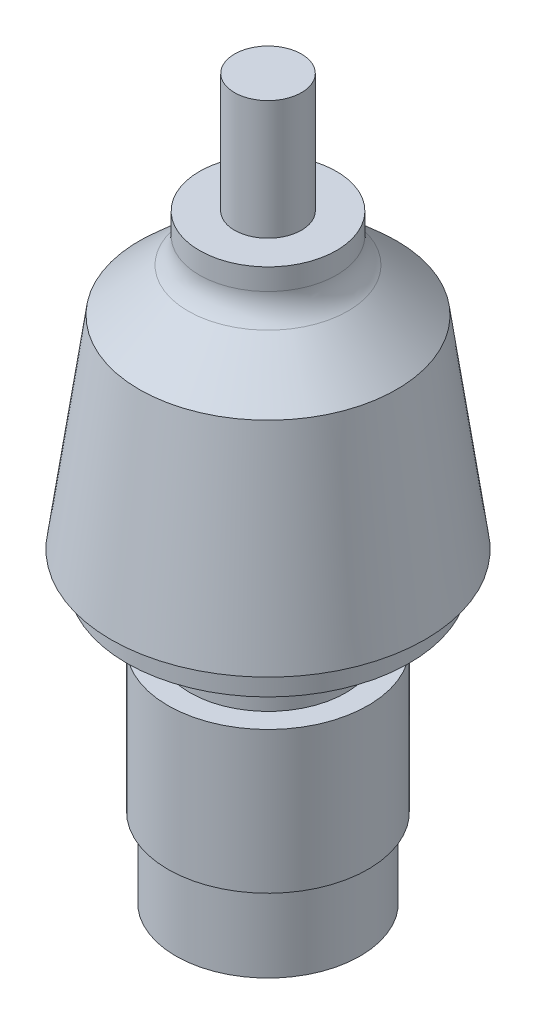
from build123d import *

# Parameters (mm, degrees)
SKETCH1_R           = 13.7541
BOSS_EXTRUDE1_DEPTH = 11.7856
SKETCH2_R           = 14.9225
BOSS_EXTRUDE2_DEPTH = 21.1582
SKETCH3_R           = 11.6205
BOSS_EXTRUDE3_DEPTH = 8.5598
SKETCH4_R           = 21.082
BOSS_EXTRUDE4_DEPTH = 4.2164
SKETCH6_R           = 19.2024
SKETCH5_R           = 23.4315
SKETCH8_R           = 10.2235
SKETCH9_R           = 10.2235
BOSS_EXTRUDE5_DEPTH = 5.461
SKETCH11_R          = 4.9911
BOSS_EXTRUDE6_DEPTH = 17.78
FILLET1_R           = 5.08


with BuildPart() as part:
    # Sketch1 → Boss-Extrude1 (new body)
    with BuildSketch(Plane(origin=(0, 0, 0), x_dir=(1, 0, 0), z_dir=(0, 1, 0))):
        with Locations(Location((0, 0, 0), (0, 0, 270))):
            Circle(SKETCH1_R)
    extrude(amount=BOSS_EXTRUDE1_DEPTH)

    # Sketch2 → Boss-Extrude2 (add)
    with BuildSketch(Plane(origin=(0, 11.7856, 0), x_dir=(1, 0, 0), z_dir=(0, 1, 0))):
        with Locations(Location((0, 0, 0), (0, 0, 270))):
            Circle(SKETCH2_R)
    extrude(amount=BOSS_EXTRUDE2_DEPTH)

    # Sketch3 → Boss-Extrude3 (add)
    with BuildSketch(Plane(origin=(0, 32.9438, 0), x_dir=(1, 0, 0), z_dir=(0, 1, 0))):
        with Locations(Location((0, 0, 0), (0, 0, 270))):
            Circle(SKETCH3_R)
    extrude(amount=BOSS_EXTRUDE3_DEPTH)

    # Sketch4 → Boss-Extrude4 (add)
    with BuildSketch(Plane(origin=(0, 41.5036, 0), x_dir=(1, 0, 0), z_dir=(0, 1, 0))):
        with Locations(Location((0, 0, 0), (0, 0, 270))):
            Circle(SKETCH4_R)
    extrude(amount=BOSS_EXTRUDE4_DEPTH)

    # Sketch6 → Loft1 section 0
    with BuildSketch(Plane(origin=(0, 75.9206, 0), x_dir=(1, 0, 0), z_dir=(0, 1, 0))):
        Circle(SKETCH6_R)
    # Sketch5 → Loft1 section 1
    with BuildSketch(Plane(origin=(0, 45.72, 0), x_dir=(1, 0, 0), z_dir=(0, 1, 0))):
        Circle(SKETCH5_R)
    loft()

    # Sketch8 → section 1 of loft2
    with BuildSketch(Plane(origin=(0, 83.9216, 0), x_dir=(1, 0, 0), z_dir=(0, 1, 0)), mode=Mode.PRIVATE) as loft2_s1:
        Circle(SKETCH8_R)
    # loft up to a face of the part (loft2)
    loft([Face(Wire([part.edges().sort_by_distance((-13.144947347, 75.9206, -13.997947171))[0]])), loft2_s1.sketch])

    # Sketch9 → Boss-Extrude5 (add)
    with BuildSketch(Plane(origin=(0, 83.9216, 0), x_dir=(1, 0, 0), z_dir=(0, 1, 0))):
        with Locations(Location((0, 0, 0), (0, 0, 270))):
            Circle(SKETCH9_R)
    extrude(amount=BOSS_EXTRUDE5_DEPTH)

    # Sketch11 → Boss-Extrude6 (add)
    with BuildSketch(Plane(origin=(0, 89.3826, 0), x_dir=(1, 0, 0), z_dir=(0, 1, 0))):
        with Locations(Location((0, 0, 0), (0, 0, 270))):
            Circle(SKETCH11_R)
    extrude(amount=BOSS_EXTRUDE6_DEPTH)

    # Fillet1
    fillet1_edges = [part.edges().sort_by_distance(p)[0] for p in [
        (-7.229106177, 83.9216, -7.229106177),
    ]]
    fillet(fillet1_edges, radius=FILLET1_R)


solid = part.part
